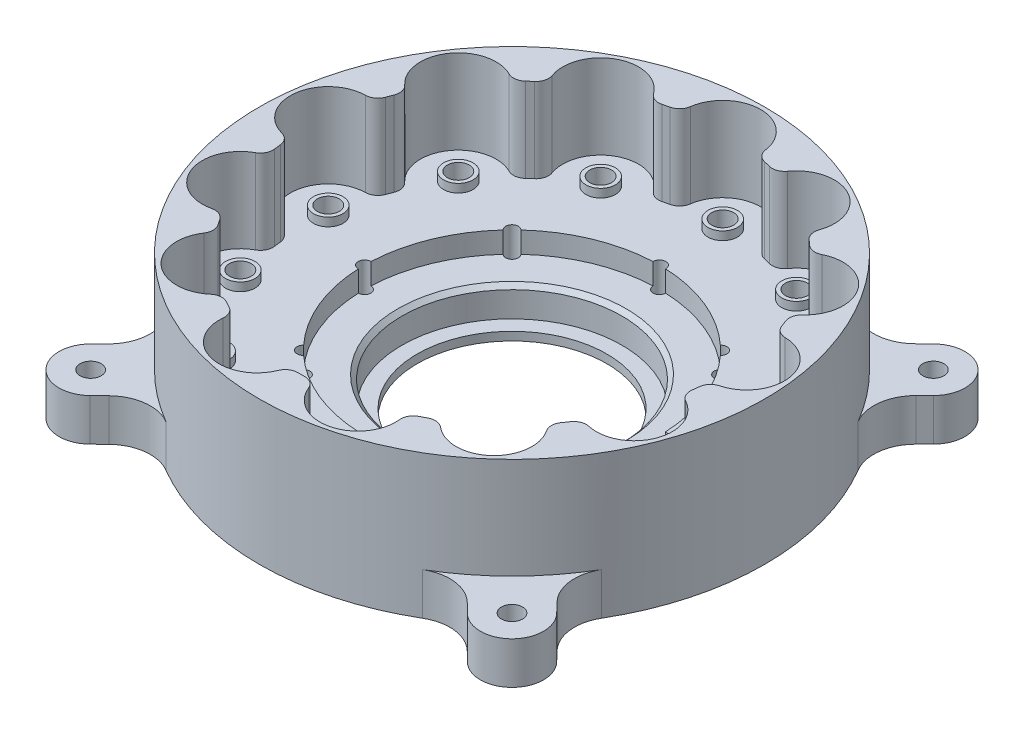
from build123d import *

# Parameters (mm, degrees)
SKETCH1_R           = 60
BOSS_EXTRUDE1_DEPTH = 9
SKETCH2_R           = 26.1
CUT_EXTRUDE1_DEPTH  = 7
SKETCH3_R           = 22.5
CUT_EXTRUDE2_DEPTH  = 8
SKETCH7_R           = 60
SKETCH7_R_2         = 35
BOSS_EXTRUDE4_DEPTH = 5
SKETCH4_R           = 2.5
CUT_EXTRUDE3_DEPTH  = 15
SKETCH5_R           = 3.5
SKETCH5_R_2         = 2.5
BOSS_EXTRUDE2_DEPTH = 2
SKETCH6_R           = 60
BOSS_EXTRUDE3_DEPTH = 20
CUT_EXTRUDE4_START  = -16
SKETCH8_R           = 2.6
SKETCH8_R_2         = 2.5
CUT_EXTRUDE4_DEPTH  = 8
SKETCH9_R           = 2.5
BOSS_EXTRUDE5_DEPTH = 10
SKETCH10_R          = 1.5
CUT_EXTRUDE5_DEPTH  = 35
CHAMFER1_SIZE       = 1
FILLET1_R           = 3


with BuildPart() as part:
    # Sketch1 → Boss-Extrude1 (new body)
    with BuildSketch(Plane(origin=(0, 0, 0), x_dir=(1, 0, 0), z_dir=(0, 1, 0))):
        Circle(SKETCH1_R)
    extrude(amount=BOSS_EXTRUDE1_DEPTH)

    # Sketch2 → Cut-Extrude1 (cut)
    with BuildSketch(Plane(origin=(0, 9, 0), x_dir=(1, 0, 0), z_dir=(0, 1, 0))):
        Circle(SKETCH2_R)
    extrude(amount=-CUT_EXTRUDE1_DEPTH, mode=Mode.SUBTRACT)

    # Sketch3 → Cut-Extrude2 (cut)
    with BuildSketch(Plane(origin=(0, 2, 0), x_dir=(1, 0, 0), z_dir=(0, 1, 0))):
        Circle(SKETCH3_R)
    extrude(amount=-CUT_EXTRUDE2_DEPTH, mode=Mode.SUBTRACT)

    # Sketch7 → Boss-Extrude4 (add)
    with BuildSketch(Plane(origin=(0, 9, 0), x_dir=(1, 0, 0), z_dir=(0, 1, 0))):
        Circle(SKETCH7_R)
        Circle(SKETCH7_R_2, mode=Mode.SUBTRACT)
    extrude(amount=BOSS_EXTRUDE4_DEPTH)

    # Sketch4 → Cut-Extrude3 (cut, through all)
    with BuildSketch(Plane(origin=(0, 14, 0), x_dir=(1, 0, 0), z_dir=(0, 1, 0))):
        with Locations((0, 50)):
            Circle(SKETCH4_R)
        with Locations((23.236158602, 44.272801283)):
            Circle(SKETCH4_R)
        with Locations((41.149193295, 28.403237337)):
            Circle(SKETCH4_R)
        with Locations((49.635443705, 6.026834013)):
            Circle(SKETCH4_R)
        with Locations((46.750812134, -17.730244352)):
            Circle(SKETCH4_R)
        with Locations((33.156132912, -37.425537409)):
            Circle(SKETCH4_R)
        with Locations((11.965783214, -48.547090871)):
            Circle(SKETCH4_R)
        with Locations((-11.965783214, -48.547090871)):
            Circle(SKETCH4_R)
        with Locations((-33.156132912, -37.425537409)):
            Circle(SKETCH4_R)
        with Locations((-46.750812134, -17.730244352)):
            Circle(SKETCH4_R)
        with Locations((-49.635443705, 6.026834013)):
            Circle(SKETCH4_R)
        with Locations((-41.149193295, 28.403237337)):
            Circle(SKETCH4_R)
        with Locations((-23.236158602, 44.272801283)):
            Circle(SKETCH4_R)
    extrude(amount=-CUT_EXTRUDE3_DEPTH, mode=Mode.SUBTRACT)

    # Sketch5 → Boss-Extrude2 (add)
    with BuildSketch(Plane(origin=(0, 14, 0), x_dir=(1, 0, 0), z_dir=(0, 1, 0))):
        with Locations((0, 50)):
            Circle(SKETCH5_R)
        with Locations((0, 50)):
            Circle(SKETCH5_R_2, mode=Mode.SUBTRACT)
        with Locations((23.236158602, 44.272801283)):
            Circle(SKETCH5_R)
        with Locations((23.236158602, 44.272801283)):
            Circle(SKETCH5_R_2, mode=Mode.SUBTRACT)
        with Locations((41.149193295, 28.403237337)):
            Circle(SKETCH5_R)
        with Locations((41.149193295, 28.403237337)):
            Circle(SKETCH5_R_2, mode=Mode.SUBTRACT)
        with Locations((49.635443705, 6.026834013)):
            Circle(SKETCH5_R)
        with Locations((49.635443705, 6.026834013)):
            Circle(SKETCH5_R_2, mode=Mode.SUBTRACT)
        with Locations((46.750812134, -17.730244352)):
            Circle(SKETCH5_R)
        with Locations((46.750812134, -17.730244352)):
            Circle(SKETCH5_R_2, mode=Mode.SUBTRACT)
        with Locations((33.156132912, -37.425537409)):
            Circle(SKETCH5_R)
        with Locations((33.156132912, -37.425537409)):
            Circle(SKETCH5_R_2, mode=Mode.SUBTRACT)
        with Locations((11.965783214, -48.547090871)):
            Circle(SKETCH5_R)
        with Locations((11.965783214, -48.547090871)):
            Circle(SKETCH5_R_2, mode=Mode.SUBTRACT)
        with Locations((-11.965783214, -48.547090871)):
            Circle(SKETCH5_R)
        with Locations((-11.965783214, -48.547090871)):
            Circle(SKETCH5_R_2, mode=Mode.SUBTRACT)
        with Locations((-33.156132912, -37.425537409)):
            Circle(SKETCH5_R)
        with Locations((-33.156132912, -37.425537409)):
            Circle(SKETCH5_R_2, mode=Mode.SUBTRACT)
        with Locations((-46.750812134, -17.730244352)):
            Circle(SKETCH5_R)
        with Locations((-46.750812134, -17.730244352)):
            Circle(SKETCH5_R_2, mode=Mode.SUBTRACT)
        with Locations((-49.635443705, 6.026834013)):
            Circle(SKETCH5_R)
        with Locations((-49.635443705, 6.026834013)):
            Circle(SKETCH5_R_2, mode=Mode.SUBTRACT)
        with Locations((-41.149193295, 28.403237337)):
            Circle(SKETCH5_R)
        with Locations((-41.149193295, 28.403237337)):
            Circle(SKETCH5_R_2, mode=Mode.SUBTRACT)
        with Locations((-23.236158602, 44.272801283)):
            Circle(SKETCH5_R)
        with Locations((-23.236158602, 44.272801283)):
            Circle(SKETCH5_R_2, mode=Mode.SUBTRACT)
    extrude(amount=BOSS_EXTRUDE2_DEPTH)

    # Sketch6 → Boss-Extrude3 (add)
    with BuildSketch(Plane(origin=(0, 14, 0), x_dir=(1, 0, 0), z_dir=(0, 1, 0))):
        Circle(SKETCH6_R)
        with BuildLine():
            ThreePointArc((8.963475888, 49.19), (0, 59), (-8.963475888, 49.19))
            ThreePointArc((-8.963475888, 49.19), (-11.965783214, 48.547090871), (-14.922969097, 47.721116849))
            ThreePointArc((-14.922969097, 47.721116849), (-27.418667151, 52.241905514), (-30.796496569, 39.390046955))
            ThreePointArc((-30.796496569, 39.390046955), (-33.156132912, 37.425537409), (-35.390741703, 35.31990093))
            ThreePointArc((-35.390741703, 35.31990093), (-48.556048088, 33.515820057), (-45.574411024, 20.566308853))
            ThreePointArc((-45.574411024, 20.566308853), (-46.750812134, 17.730244352), (-47.75092189, 14.827321359))
            ThreePointArc((-47.75092189, 14.827321359), (-58.569823572, 7.111664135), (-49.911777144, -2.968922755))
            ThreePointArc((-49.911777144, -2.968922755), (-49.635443705, -6.026834013), (-49.171941333, -9.062018847))
            ThreePointArc((-49.171941333, -9.062018847), (-55.165958318, -20.921688336), (-42.814956623, -25.82400994))
            ThreePointArc((-42.814956623, -25.82400994), (-41.149193295, -28.403237337), (-39.328261602, -30.875359744))
            ThreePointArc((-39.328261602, -30.875359744), (-39.124236836, -44.162134142), (-25.909745516, -42.763127661))
            ThreePointArc((-25.909745516, -42.763127661), (-23.236158602, -44.272801283), (-20.474951096, -45.615527813))
            ThreePointArc((-20.474951096, -45.615527813), (-14.119624193, -57.285567228), (-3.068923957, -49.905728186))
            ThreePointArc((-3.068923957, -49.905728186), (0, -50), (3.068923957, -49.905728186))
            ThreePointArc((3.068923957, -49.905728186), (14.119624193, -57.285567228), (20.474951096, -45.615527813))
            ThreePointArc((20.474951096, -45.615527813), (23.236158602, -44.272801283), (25.909745516, -42.763127661))
            ThreePointArc((25.909745516, -42.763127661), (39.124236836, -44.162134142), (39.328261602, -30.875359744))
            ThreePointArc((39.328261602, -30.875359744), (41.149193295, -28.403237337), (42.814956623, -25.82400994))
            ThreePointArc((42.814956623, -25.82400994), (55.165958318, -20.921688336), (49.171941333, -9.062018847))
            ThreePointArc((49.171941333, -9.062018847), (49.635443705, -6.026834013), (49.911777144, -2.968922755))
            ThreePointArc((49.911777144, -2.968922755), (58.569823572, 7.111664135), (47.75092189, 14.827321359))
            ThreePointArc((47.75092189, 14.827321359), (46.750812134, 17.730244352), (45.574411024, 20.566308853))
            ThreePointArc((45.574411024, 20.566308853), (48.556048088, 33.515820057), (35.390741703, 35.31990093))
            ThreePointArc((35.390741703, 35.31990093), (33.156132912, 37.425537409), (30.796496569, 39.390046955))
            ThreePointArc((30.796496569, 39.390046955), (27.418667151, 52.241905514), (14.922969097, 47.721116849))
            ThreePointArc((14.922969097, 47.721116849), (11.965783214, 48.547090871), (8.963475888, 49.19))
        make_face(mode=Mode.SUBTRACT)
    extrude(amount=BOSS_EXTRUDE3_DEPTH)

    # Sketch8 → Cut-Extrude4 (cut)
    with BuildSketch(Plane.XZ.offset(CUT_EXTRUDE4_START)):
        with Locations((23.236158602, -44.272801283)):
            Circle(SKETCH8_R)
        with Locations((23.236158602, -44.272801283)):
            Circle(SKETCH8_R_2, mode=Mode.SUBTRACT)
        with Locations((41.149193295, -28.403237337)):
            Circle(SKETCH8_R)
        with Locations((41.149193295, -28.403237337)):
            Circle(SKETCH8_R_2, mode=Mode.SUBTRACT)
        with Locations((49.635443705, -6.026834013)):
            Circle(SKETCH8_R)
        with Locations((49.635443705, -6.026834013)):
            Circle(SKETCH8_R_2, mode=Mode.SUBTRACT)
        with Locations((46.750812134, 17.730244352)):
            Circle(SKETCH8_R)
        with Locations((46.750812134, 17.730244352)):
            Circle(SKETCH8_R_2, mode=Mode.SUBTRACT)
        with Locations((33.156132912, 37.425537409)):
            Circle(SKETCH8_R)
        with Locations((33.156132912, 37.425537409)):
            Circle(SKETCH8_R_2, mode=Mode.SUBTRACT)
        with Locations((11.965783214, 48.547090871)):
            Circle(SKETCH8_R)
        with Locations((11.965783214, 48.547090871)):
            Circle(SKETCH8_R_2, mode=Mode.SUBTRACT)
        with Locations((-11.965783214, 48.547090871)):
            Circle(SKETCH8_R)
        with Locations((-11.965783214, 48.547090871)):
            Circle(SKETCH8_R_2, mode=Mode.SUBTRACT)
        with Locations((-33.156132912, 37.425537409)):
            Circle(SKETCH8_R)
        with Locations((-33.156132912, 37.425537409)):
            Circle(SKETCH8_R_2, mode=Mode.SUBTRACT)
        with Locations((-46.750812134, 17.730244352)):
            Circle(SKETCH8_R)
        with Locations((-46.750812134, 17.730244352)):
            Circle(SKETCH8_R_2, mode=Mode.SUBTRACT)
        with Locations((-49.635443705, -6.026834013)):
            Circle(SKETCH8_R)
        with Locations((-49.635443705, -6.026834013)):
            Circle(SKETCH8_R_2, mode=Mode.SUBTRACT)
        with Locations((-41.149193295, -28.403237337)):
            Circle(SKETCH8_R)
        with Locations((-41.149193295, -28.403237337)):
            Circle(SKETCH8_R_2, mode=Mode.SUBTRACT)
        with Locations((-23.236158602, -44.272801283)):
            Circle(SKETCH8_R)
        with Locations((-23.236158602, -44.272801283)):
            Circle(SKETCH8_R_2, mode=Mode.SUBTRACT)
        with Locations((0, -50)):
            Circle(SKETCH8_R)
        with Locations((0, -50)):
            Circle(SKETCH8_R_2, mode=Mode.SUBTRACT)
    extrude(amount=CUT_EXTRUDE4_DEPTH, mode=Mode.SUBTRACT)

    # Sketch9 → Boss-Extrude5 (add)
    with BuildSketch(Plane(origin=(0, 0, 0), x_dir=(-1, 0, 0), z_dir=(0, -1, 0))):
        with BuildLine():
            Line((-44.696699141, -55.303300859), (-42.622422923, -53.229024641))
            ThreePointArc((-42.622422923, -53.229024641), (-36.811398036, -50.37979549), (-30.472590095, -51.685793531))
            ThreePointArc((-30.472590095, -51.685793531), (-42.442730976, -42.410076483), (-51.709232173, -30.432799873))
            ThreePointArc((-51.709232173, -30.432799873), (-50.397327539, -36.685151584), (-53.13819827, -42.455820811))
            Line((-53.13819827, -42.455820811), (-55.391929449, -44.78683428))
            ThreePointArc((-55.391929449, -44.78683428), (-55.258420018, -55.347805056), (-44.696699141, -55.303300859))
        make_face()
        with Locations((-50, -50)):
            Circle(SKETCH9_R, mode=Mode.SUBTRACT)
        with BuildLine():
            Line((-55.303300859, 44.696699141), (-53.229024641, 42.622422923))
            ThreePointArc((-53.229024641, 42.622422923), (-50.37979549, 36.811398036), (-51.685793531, 30.472590095))
            ThreePointArc((-51.685793531, 30.472590095), (-42.410076483, 42.442730976), (-30.432799873, 51.709232173))
            ThreePointArc((-30.432799873, 51.709232173), (-36.685151584, 50.397327539), (-42.455820811, 53.13819827))
            Line((-42.455820811, 53.13819827), (-44.78683428, 55.391929449))
            ThreePointArc((-44.78683428, 55.391929449), (-55.347805056, 55.258420018), (-55.303300859, 44.696699141))
        make_face()
        with Locations((-50, 50)):
            Circle(SKETCH9_R, mode=Mode.SUBTRACT)
        with BuildLine():
            Line((44.696699141, 55.303300859), (42.622422923, 53.229024641))
            ThreePointArc((42.622422923, 53.229024641), (36.811398036, 50.37979549), (30.472590095, 51.685793531))
            ThreePointArc((30.472590095, 51.685793531), (42.442730976, 42.410076483), (51.709232173, 30.432799873))
            ThreePointArc((51.709232173, 30.432799873), (50.397327539, 36.685151584), (53.13819827, 42.455820811))
            Line((53.13819827, 42.455820811), (55.391929449, 44.78683428))
            ThreePointArc((55.391929449, 44.78683428), (55.258420018, 55.347805056), (44.696699141, 55.303300859))
        make_face()
        with Locations((50, 50)):
            Circle(SKETCH9_R, mode=Mode.SUBTRACT)
        with BuildLine():
            Line((55.303300859, -44.696699141), (53.229024641, -42.622422923))
            ThreePointArc((53.229024641, -42.622422923), (50.37979549, -36.811398036), (51.685793531, -30.472590095))
            ThreePointArc((51.685793531, -30.472590095), (42.410076483, -42.442730976), (30.432799873, -51.709232173))
            ThreePointArc((30.432799873, -51.709232173), (36.685151584, -50.397327539), (42.455820811, -53.13819827))
            Line((42.455820811, -53.13819827), (44.78683428, -55.391929449))
            ThreePointArc((44.78683428, -55.391929449), (55.347805056, -55.258420018), (55.303300859, -44.696699141))
        make_face()
        with Locations((50, -50)):
            Circle(SKETCH9_R, mode=Mode.SUBTRACT)
    extrude(amount=-BOSS_EXTRUDE5_DEPTH)

    # Sketch10 → Cut-Extrude5 (cut, through all)
    with BuildSketch(Plane(origin=(0, 0, 0), x_dir=(-1, 0, 0), z_dir=(0, -1, 0))):
        with Locations((35, 0)):
            Circle(SKETCH10_R)
        with Locations((24.748737342, -24.748737342)):
            Circle(SKETCH10_R)
        with Locations((0, -35)):
            Circle(SKETCH10_R)
        with Locations((-24.748737342, -24.748737342)):
            Circle(SKETCH10_R)
        with Locations((-35, 0)):
            Circle(SKETCH10_R)
        with Locations((-24.748737342, 24.748737342)):
            Circle(SKETCH10_R)
        with Locations((0, 35)):
            Circle(SKETCH10_R)
        with Locations((24.748737342, 24.748737342)):
            Circle(SKETCH10_R)
    extrude(amount=-CUT_EXTRUDE5_DEPTH, mode=Mode.SUBTRACT)

    # Chamfer1
    chamfer1_edges = [part.edges().sort_by_distance(p)[0] for p in [
        (-26.1, 9, 0),
    ]]
    chamfer(chamfer1_edges, length=CHAMFER1_SIZE)

    # Fillet1
    fillet1_edges = [part.edges().sort_by_distance(p)[0] for p in [
        (14.922969097, 24, -47.721116849),
        (8.963475888, 24, -49.19),
        (-8.963475888, 24, -49.19),
        (-14.922969097, 24, -47.721116849),
        (-30.796496569, 24, -39.390046955),
        (-35.390741703, 24, -35.31990093),
        (-45.574411024, 24, -20.566308853),
        (-47.75092189, 24, -14.827321359),
        (-49.911777144, 24, 2.968922755),
        (-49.171941333, 24, 9.062018847),
        (-42.814956623, 24, 25.82400994),
        (-39.328261602, 24, 30.875359744),
        (-25.909745516, 24, 42.763127661),
        (-20.474951096, 24, 45.615527813),
        (-3.068923957, 24, 49.905728186),
        (3.068923957, 24, 49.905728186),
        (20.474951096, 24, 45.615527813),
        (25.909745516, 24, 42.763127661),
        (39.328261602, 24, 30.875359744),
        (42.814956623, 24, 25.82400994),
        (49.171941333, 24, 9.062018847),
        (49.911777144, 24, 2.968922755),
        (47.75092189, 24, -14.827321359),
        (45.574411024, 24, -20.566308853),
        (35.390741703, 24, -35.31990093),
        (30.796496569, 24, -39.390046955),
    ]]
    fillet(fillet1_edges, radius=FILLET1_R)


solid = part.part
